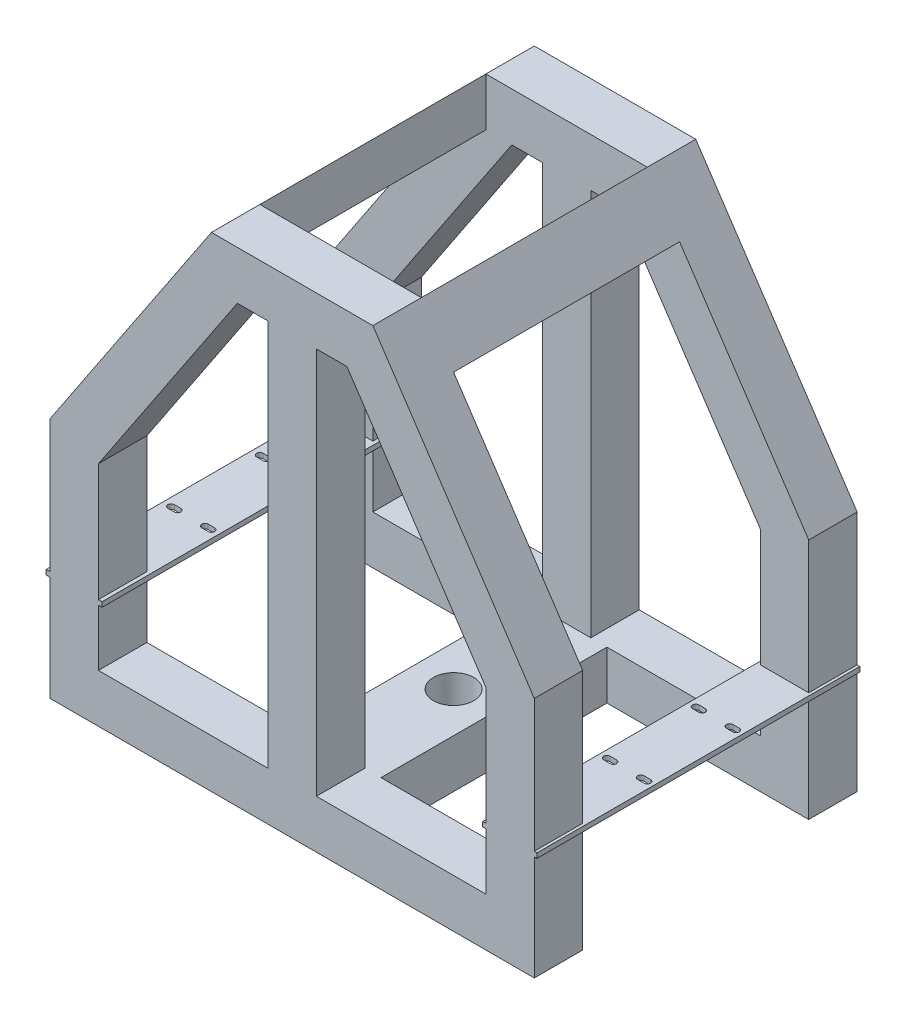
from build123d import *

# Parameters (mm, degrees)
BOSS_EXTRUDE4_DEPTH = 200
SKETCH5_W           = 300
SKETCH5_H           = 140
CUT_EXTRUDE3_DEPTH  = 270
SKETCH6_W           = 2.411871081
SKETCH6_H           = 3
SKETCH6_W_2         = 30
SKETCH6_W_3         = 2.243969638
SKETCH6_W_4         = 1.678083374
SKETCH6_W_5         = 1.954362123
BOSS_EXTRUDE6_DEPTH = 200
SKETCH7_W           = 100
SKETCH7_H           = 140
CUT_EXTRUDE4_DEPTH  = 174
SKETCH9_W           = 50
SKETCH9_H           = 30
BOSS_EXTRUDE7_DEPTH = 193
SKETCH10_R          = 12.5
CUT_EXTRUDE5_DEPTH  = 193
CUT_EXTRUDE23_DEPTH = 10


with BuildPart() as part:
    # Sketch1 → Boss-Extrude4 (new body)
    with BuildSketch(Plane.XY):
        Polygon((1.862238879, 123.981049527), (1.862238879, 153.981049527), (-33.137761121, 153.981049527), (-133.137761121, 3.981049527), (-133.137761121, -146.018950473), (-53.137761121, -146.018950473), (86.862238879, -146.018950473), (166.862238879, -146.018950473), (166.862238879, 3.981049527), (66.862238879, 153.981049527), (31.862238879, 153.981049527), (31.862238879, 123.981049527), (50.806726124, 123.981049527), (136.862238879, -5.102219605), (136.862238879, -116.018950473), (31.862238879, -116.018950473), (31.862238879, -46.018950473), (1.862238879, -46.018950473), (1.862238879, -116.018950473), (-103.137761121, -116.018950473), (-103.137761121, -5.102219605), (-17.082248367, 123.981049527), align=None)
        Polygon((31.862238879, 153.981049527), (1.862238879, 153.981049527), (1.862238879, 123.981049527), (1.862238879, -46.018950473), (31.862238879, -46.018950473), (31.862238879, 123.981049527), align=None)
    extrude(amount=BOSS_EXTRUDE4_DEPTH)

    # Sketch5 → Cut-Extrude3 (cut)
    with BuildSketch(Plane.XZ.offset(146.018950473)):
        with Locations((16.862238879, 100)):
            Rectangle(SKETCH5_W, SKETCH5_H)
    extrude(amount=-CUT_EXTRUDE3_DEPTH, mode=Mode.SUBTRACT)

    # Sketch6 → Boss-Extrude6 (add)
    with BuildSketch(Plane.XY.offset(200)):
        with Locations((-134.343696662, -79.518950473)):
            Rectangle(SKETCH6_W, SKETCH6_H)
        with Locations((-118.137761121, -79.518950473)):
            Rectangle(SKETCH6_W_2, SKETCH6_H)
        with Locations((-102.015776302, -79.518950473)):
            Rectangle(SKETCH6_W_3, SKETCH6_H)
        with Locations((151.862238879, -79.518950473)):
            Rectangle(SKETCH6_W_2, SKETCH6_H)
        with Locations((167.701280566, -79.518950473)):
            Rectangle(SKETCH6_W_4, SKETCH6_H)
        with Locations((135.885057818, -79.518950473)):
            Rectangle(SKETCH6_W_5, SKETCH6_H)
    extrude(amount=-BOSS_EXTRUDE6_DEPTH)

    # Sketch7 → Cut-Extrude4 (cut)
    with BuildSketch(Plane(origin=(0, 153.981049527, 0), x_dir=(1, 0, 0), z_dir=(0, 1, 0))):
        with Locations((16.862238879, -100)):
            Rectangle(SKETCH7_W, SKETCH7_H)
    extrude(amount=-CUT_EXTRUDE4_DEPTH, mode=Mode.SUBTRACT)

    # Sketch9 → Boss-Extrude7 (add)
    with BuildSketch(Plane(origin=(0, 0, 0), x_dir=(-1, 0, 0), z_dir=(0, 0, -1))):
        with Locations((-16.862238879, -131.018950473)):
            Rectangle(SKETCH9_W, SKETCH9_H)
    extrude(amount=-BOSS_EXTRUDE7_DEPTH)

    # Sketch10 → Cut-Extrude5 (cut)
    with BuildSketch(Plane.XZ.offset(146.018950473)):
        with Locations((16.862238879, 100)):
            Circle(SKETCH10_R)
    extrude(amount=-CUT_EXTRUDE5_DEPTH, mode=Mode.SUBTRACT)

    # Sketch11 → Cut-Extrude23 (cut)
    with BuildSketch(Plane(origin=(0, -78.018950473, 0), x_dir=(1, 0, 0), z_dir=(0, 1, 0))):
        with BuildLine():
            Line((139.362238879, -125.5), (143.362238879, -125.5))
            ThreePointArc((143.362238879, -125.5), (145.362238879, -127.5), (143.362238879, -129.5))
            Line((143.362238879, -129.5), (139.362238879, -129.5))
            ThreePointArc((139.362238879, -129.5), (137.362238879, -127.5), (139.362238879, -125.5))
        make_face()
        with BuildLine():
            Line((164.362238879, -125.5), (160.362238879, -125.5))
            ThreePointArc((160.362238879, -125.5), (158.362238879, -127.5), (160.362238879, -129.5))
            Line((160.362238879, -129.5), (164.362238879, -129.5))
            ThreePointArc((164.362238879, -129.5), (166.362238879, -127.5), (164.362238879, -125.5))
        make_face()
        with BuildLine():
            Line((164.362238879, -74.5), (160.362238879, -74.5))
            ThreePointArc((160.362238879, -74.5), (158.362238879, -72.5), (160.362238879, -70.5))
            Line((160.362238879, -70.5), (164.362238879, -70.5))
            ThreePointArc((164.362238879, -70.5), (166.362238879, -72.5), (164.362238879, -74.5))
        make_face()
        with BuildLine():
            Line((139.362238879, -74.5), (143.362238879, -74.5))
            ThreePointArc((143.362238879, -74.5), (145.362238879, -72.5), (143.362238879, -70.5))
            Line((143.362238879, -70.5), (139.362238879, -70.5))
            ThreePointArc((139.362238879, -70.5), (137.362238879, -72.5), (139.362238879, -74.5))
        make_face()
        with BuildLine():
            Line((-130.637761121, -125.5), (-126.637761121, -125.5))
            ThreePointArc((-126.637761121, -125.5), (-124.637761121, -127.5), (-126.637761121, -129.5))
            Line((-126.637761121, -129.5), (-130.637761121, -129.5))
            ThreePointArc((-130.637761121, -129.5), (-132.637761121, -127.5), (-130.637761121, -125.5))
        make_face()
        with BuildLine():
            Line((-105.637761121, -125.5), (-109.637761121, -125.5))
            ThreePointArc((-109.637761121, -125.5), (-111.637761121, -127.5), (-109.637761121, -129.5))
            Line((-109.637761121, -129.5), (-105.637761121, -129.5))
            ThreePointArc((-105.637761121, -129.5), (-103.637761121, -127.5), (-105.637761121, -125.5))
        make_face()
        with BuildLine():
            Line((-130.637761121, -74.5), (-126.637761121, -74.5))
            ThreePointArc((-126.637761121, -74.5), (-124.637761121, -72.5), (-126.637761121, -70.5))
            Line((-126.637761121, -70.5), (-130.637761121, -70.5))
            ThreePointArc((-130.637761121, -70.5), (-132.637761121, -72.5), (-130.637761121, -74.5))
        make_face()
        with BuildLine():
            Line((-105.637761121, -74.5), (-109.637761121, -74.5))
            ThreePointArc((-109.637761121, -74.5), (-111.637761121, -72.5), (-109.637761121, -70.5))
            Line((-109.637761121, -70.5), (-105.637761121, -70.5))
            ThreePointArc((-105.637761121, -70.5), (-103.637761121, -72.5), (-105.637761121, -74.5))
        make_face()
    extrude(amount=-CUT_EXTRUDE23_DEPTH, mode=Mode.SUBTRACT)


solid = part.part
